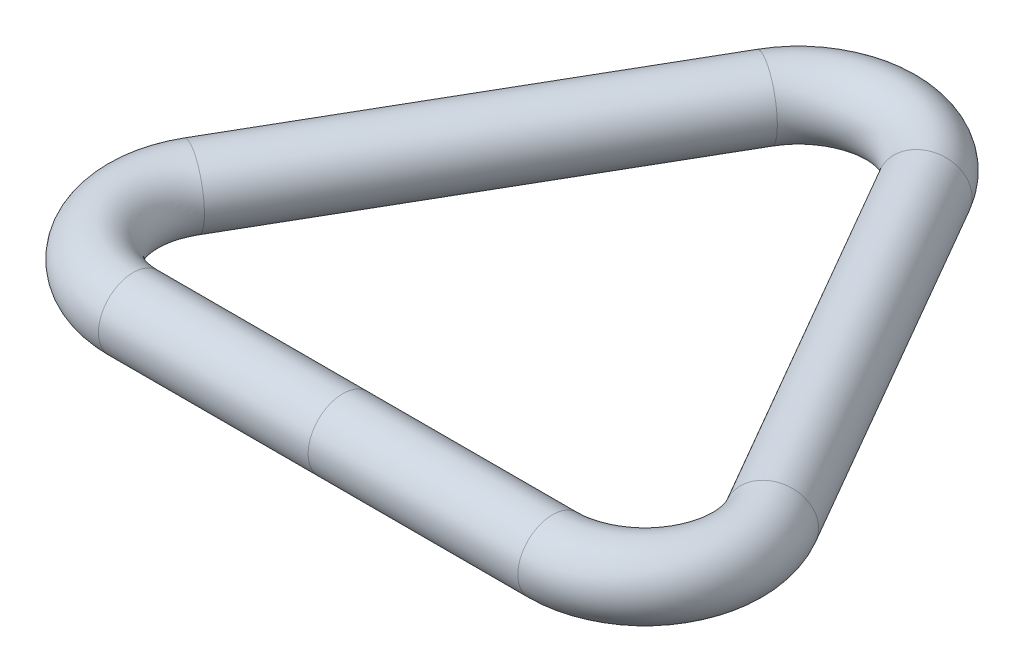
from build123d import *

# Parameters (mm, degrees)
SKETCH2_R = 4.7625


with BuildPart() as part:
    # Sweep1: sweep along a path in Sketch1
    with BuildLine(Plane(origin=(0, 0, 0), x_dir=(1, 0, 0), z_dir=(0, 1, 0))) as sweep1_path:
        Line((-10.998522628, 39.60878735), (-39.801477372, -10.279393675))
        ThreePointArc((-39.801477372, -10.279393675), (-39.801477372, -22.979393675), (-28.802954744, -29.329393675))
        Line((-28.802954744, -29.329393675), (28.802954744, -29.329393675))
        ThreePointArc((28.802954744, -29.329393675), (39.801477372, -22.979393675), (39.801477372, -10.279393675))
        Line((39.801477372, -10.279393675), (10.998522628, 39.60878735))
        ThreePointArc((10.998522628, 39.60878735), (0, 45.95878735), (-10.998522628, 39.60878735))
    # Sketch2 → Sweep1 (sweep)
    with BuildSketch(Plane(origin=(0, 0, 0), x_dir=(0, 0, -1), z_dir=(1, 0, 0))):
        with Locations((-29.329393675, 0)):
            Circle(SKETCH2_R)
    sweep(path=sweep1_path.line)


solid = part.part
